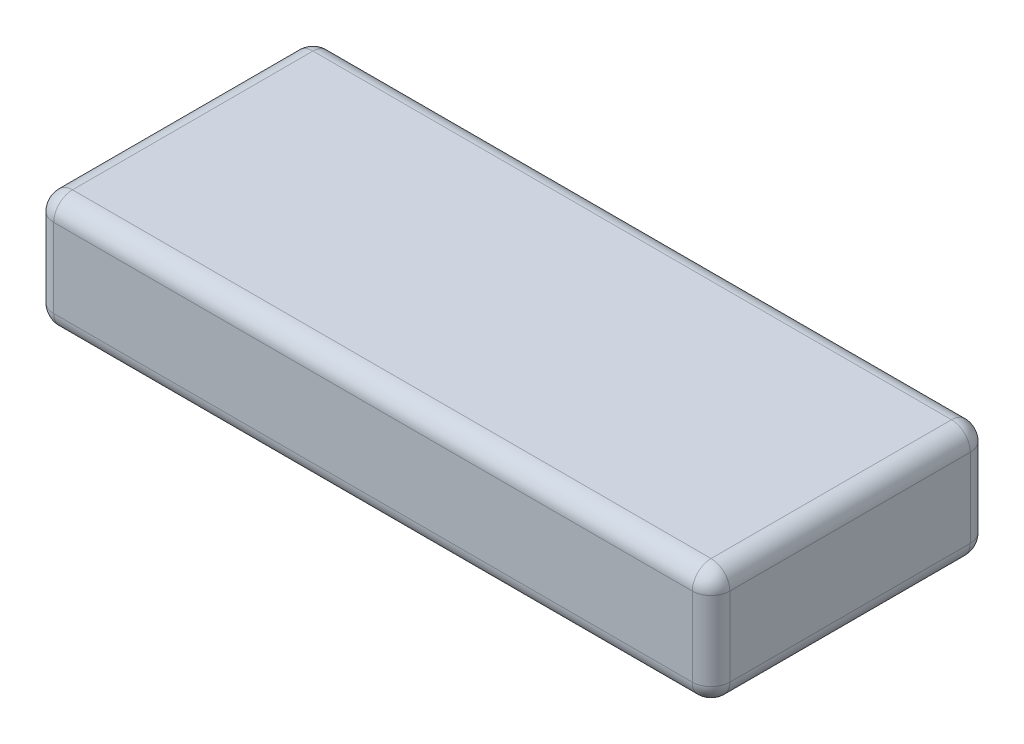
from build123d import *

# Parameters (mm, degrees)
SKETCH1_W           = 180
SKETCH1_H           = 74
BOSS_EXTRUDE1_DEPTH = 31
FILLET1_R           = 5


with BuildPart() as part:
    # Sketch1 → Boss-Extrude1 (new body)
    with BuildSketch(Plane(origin=(0, 0, 0), x_dir=(1, 0, 0), z_dir=(0, 1, 0))):
        Rectangle(SKETCH1_W, SKETCH1_H)
    extrude(amount=BOSS_EXTRUDE1_DEPTH)

    # Fillet1
    fillet1_edges = [part.edges().sort_by_distance(p)[0] for p in [
        (-90, 31, 0),
        (0, 31, 37),
        (90, 31, 0),
        (0, 0, 37),
        (-90, 0, 0),
        (0, 0, -37),
        (90, 0, 0),
        (90, 15.5, 37),
        (-90, 15.5, 37),
        (-90, 15.5, -37),
        (90, 15.5, -37),
        (0, 31, -37),
    ]]
    fillet(fillet1_edges, radius=FILLET1_R)


solid = part.part
